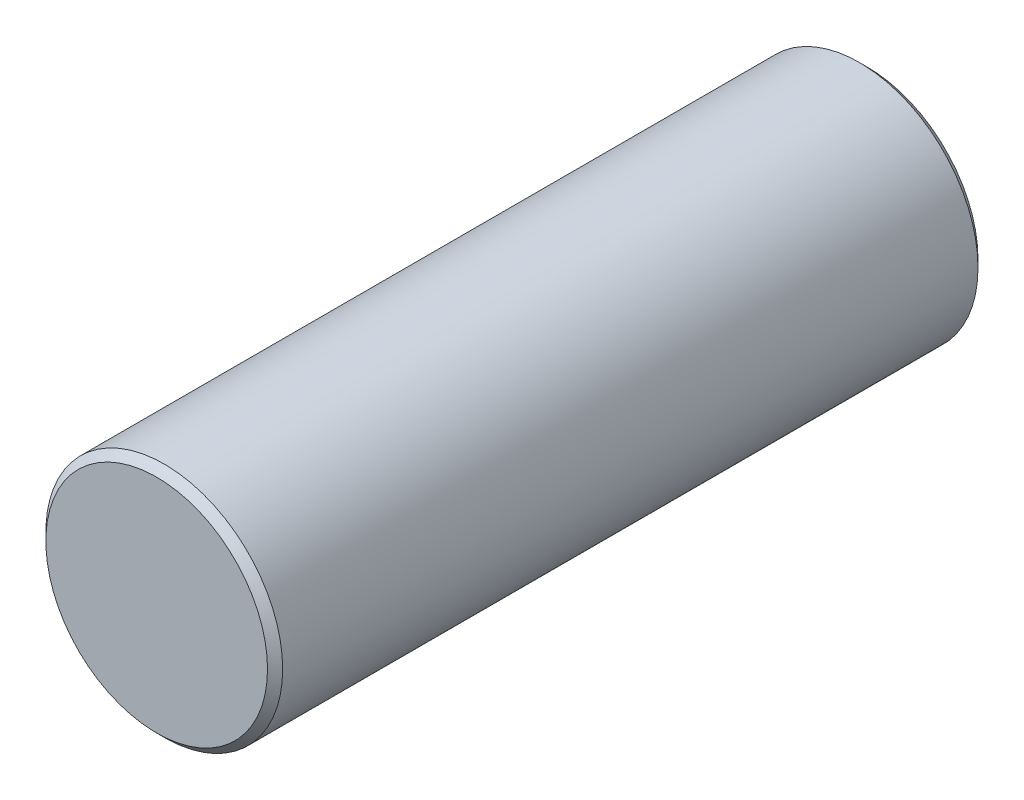
from build123d import *

# Parameters (mm, degrees)
SKETCH1_R      = 6.35
EXTRUDE1_DEPTH = 19.05
CHAMFER1_SIZE  = 0.4064


with BuildPart() as part:
    # Sketch1 → Extrude1 (new body, symmetric)
    with BuildSketch(Plane.XY):
        Circle(SKETCH1_R)
    extrude(amount=EXTRUDE1_DEPTH, both=True)

    # Chamfer1
    chamfer1_edges = [part.edges().sort_by_distance(p)[0] for p in [
        (-6.35, 0, -19.05),
        (-6.35, 0, 19.05),
    ]]
    chamfer(chamfer1_edges, length=CHAMFER1_SIZE)


solid = part.part
